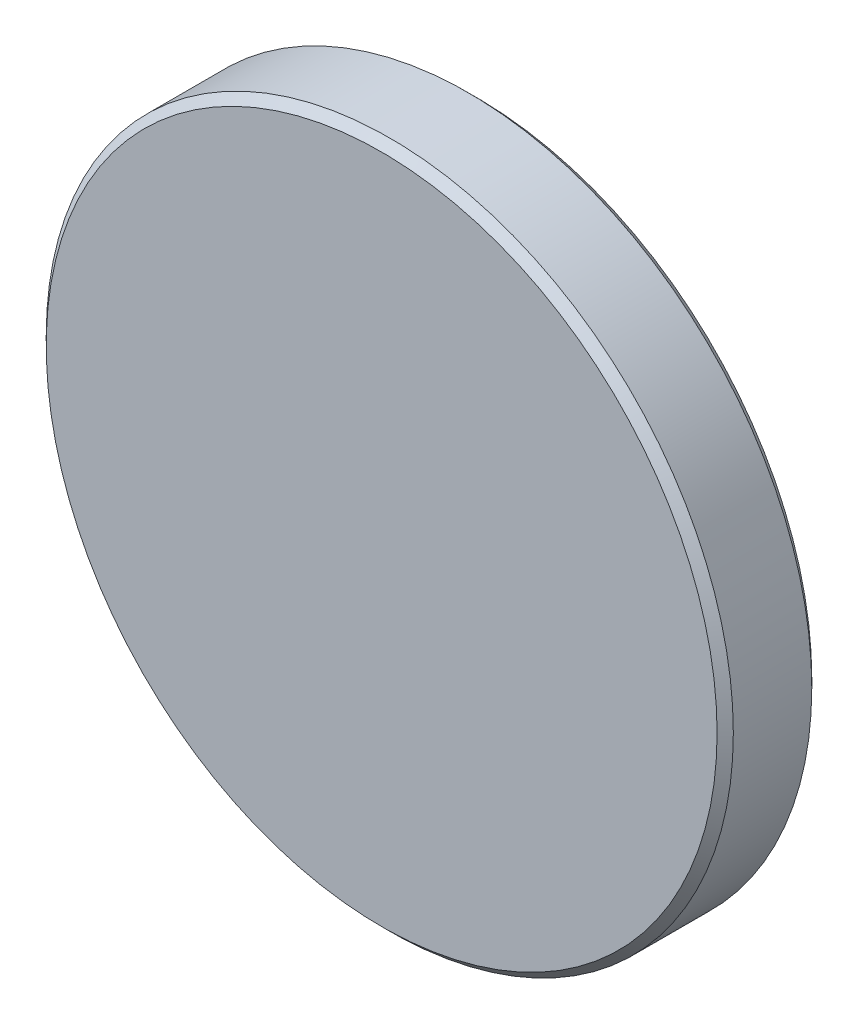
from build123d import *

# Parameters (mm, degrees)
SKETCH_1_R      = 12.7
EXTRUDE_1_DEPTH = 3.5
CHAMFER_1_SIZE  = 0.3


with BuildPart() as part:
    # 草图1 → 凸台-拉伸1 (new body)
    with BuildSketch(Plane.XY):
        Circle(SKETCH_1_R)
    extrude(amount=EXTRUDE_1_DEPTH)

    # 倒角1
    chamfer_1_edges = [part.edges().sort_by_distance(p)[0] for p in [
        (-12.7, 0, 0),
        (-12.7, 0, 3.5),
    ]]
    chamfer(chamfer_1_edges, length=CHAMFER_1_SIZE)


solid = part.part
